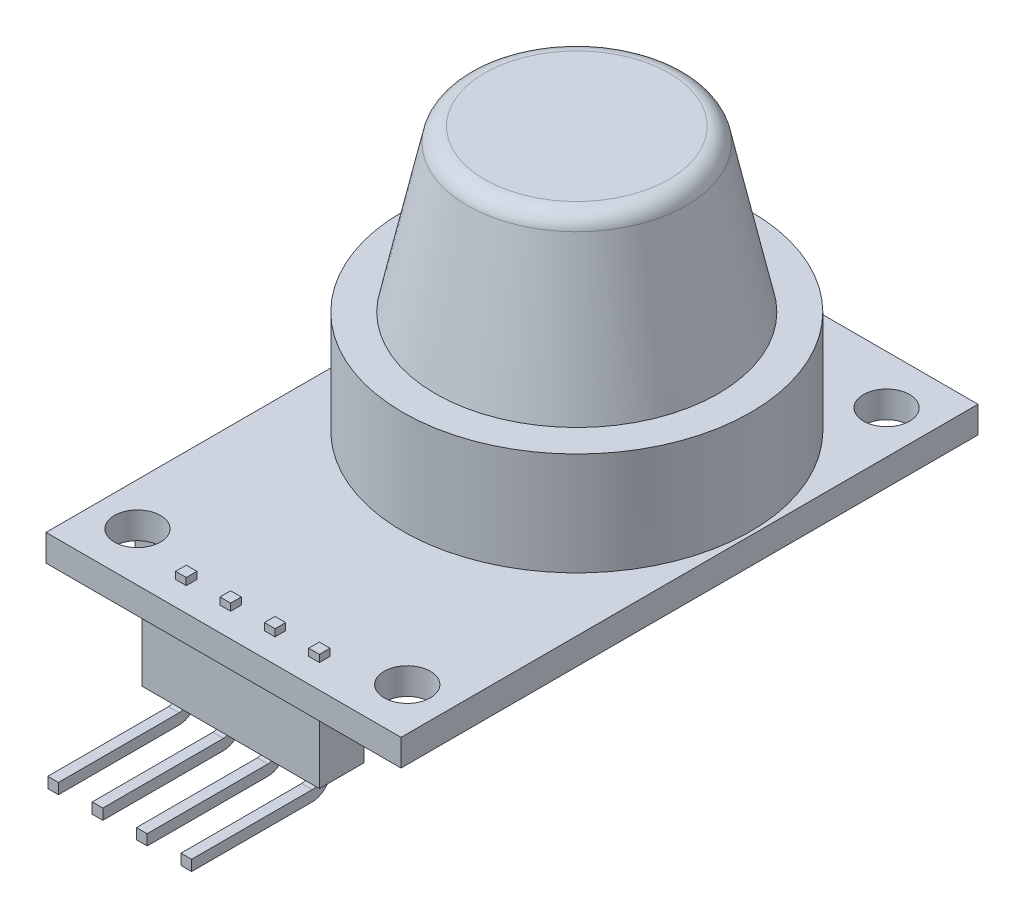
from build123d import *

# Parameters (mm, degrees)
SKETCH_1_W                 = 20
SKETCH_1_H                 = 32.5
SKETCH_1_R                 = 1.3
EXTRUDE_1_DEPTH            = 1.5
SKETCH_2_R                 = 9.8
EXTRUDE_2_DEPTH            = 5.8
FILLET_1_R                 = 1
SKETCH_4_W                 = 6.7
SKETCH_4_H                 = 6.7
EXTRUDE_3_DEPTH            = 4.8
SKETCH_5_R                 = 0.5
EXTRUDE_4_DEPTH            = 4.6
SKETCH_6_W                 = 2.5
SKETCH_6_H                 = 2.5
EXTRUDE_5_DEPTH            = 3.7
EXTRUDE_6_DEPTH            = 0.3
PATTERN_LINEAR_1_COUNT     = 3
PATTERN_LINEAR_1_PITCH     = 2.5
PATTERN_LINEAR_1_COL_COUNT = 2
PATTERN_LINEAR_1_COL_PITCH = 2.5


with BuildPart() as part:
    # 草图1 → 凸台-拉伸1 (new body)
    with BuildSketch(Plane(origin=(0, 0, 0), x_dir=(1, 0, 0), z_dir=(0, 1, 0))):
        Rectangle(SKETCH_1_W, SKETCH_1_H)
        with Locations((7.6, 13.5)):
            Circle(SKETCH_1_R, mode=Mode.SUBTRACT)
        with Locations((-7.6, 13.5)):
            Circle(SKETCH_1_R, mode=Mode.SUBTRACT)
        with Locations((-7.6, -13.5)):
            Circle(SKETCH_1_R, mode=Mode.SUBTRACT)
        with Locations((7.6, -13.5)):
            Circle(SKETCH_1_R, mode=Mode.SUBTRACT)
    extrude(amount=EXTRUDE_1_DEPTH)

    # 草图2 → 凸台-拉伸2 (add)
    with BuildSketch(Plane(origin=(0, 1.5, 0), x_dir=(1, 0, 0), z_dir=(0, 1, 0))):
        with Locations((0, 3.65)):
            Circle(SKETCH_2_R)
    extrude(amount=EXTRUDE_2_DEPTH)

    # 草图3 → 旋转1 (revolve)
    with BuildSketch(Plane(origin=(0, 0, 0), x_dir=(0, 0, -1), z_dir=(1, 0, 0))):
        Polygon((3.65, 7.163786099), (11.65, 7.163786099), (9.65, 16.363786099), (3.65, 16.363786099), align=None)
    revolve(axis=Axis((0, 2.048350332, -3.65), (0, 1, 0)))

    # 圆角1
    fillet_1_edges = [part.edges().sort_by_distance(p)[0] for p in [
        (0, 16.363786099, 2.35),
    ]]
    fillet(fillet_1_edges, radius=FILLET_1_R)

    # 草图4 → 凸台-拉伸3 (add)
    with BuildSketch(Plane.XZ):
        with Locations((-6.45, 8.1)):
            Rectangle(SKETCH_4_W, SKETCH_4_H)
    extrude(amount=EXTRUDE_3_DEPTH)

    # 草图5 → 凸台-拉伸4 (add)
    with BuildSketch(Plane.XZ):
        with Locations((4.75, -3.65)):
            Circle(SKETCH_5_R)
        with Locations((3.358757211, -7.008757211)):
            Circle(SKETCH_5_R)
        with Locations((-3.358757211, -7.008757211)):
            Circle(SKETCH_5_R)
        with Locations((-4.75, -3.65)):
            Circle(SKETCH_5_R)
        with Locations((-3.358757211, -0.291242789)):
            Circle(SKETCH_5_R)
        with Locations((3.358757211, -0.291242789)):
            Circle(SKETCH_5_R)
    extrude(amount=EXTRUDE_4_DEPTH)

    # 草图6 → 凸台-拉伸5 (add)
    with BuildSketch(Plane.XZ):
        with Locations((1.25, 14.6)):
            Rectangle(SKETCH_6_W, SKETCH_6_H)
    extrude_5 = extrude(amount=EXTRUDE_5_DEPTH)

    # 草图7 → 凸台-拉伸6 (add, symmetric)
    with BuildSketch(Plane(origin=(1.25, 0, 0), x_dir=(0, 0, -1), z_dir=(1, 0, 0))):
        with BuildLine():
            Line((-14.3, 1.9), (-14.9, 1.9))
            Line((-14.9, 1.9), (-14.9, -4.1))
            ThreePointArc((-14.9, -4.1), (-15.017157288, -4.382842712), (-15.3, -4.5))
            Line((-15.3, -4.5), (-22.1, -4.5))
            Line((-22.1, -4.5), (-22.1, -5.1))
            Line((-22.1, -5.1), (-15.3, -5.1))
            ThreePointArc((-15.3, -5.1), (-14.592893219, -4.807106781), (-14.3, -4.1))
            Line((-14.3, -4.1), (-14.3, 1.9))
        make_face()
    extrude_6 = extrude(amount=EXTRUDE_6_DEPTH, both=True)

    # 阵列(线性)1: 凸台-拉伸5, 凸台-拉伸6 ×3
    with Locations(*[(-i * PATTERN_LINEAR_1_PITCH, 0, 0) for i in range(1, PATTERN_LINEAR_1_COUNT)]):
        add(extrude_5)
        add(extrude_6)

    # 阵列(线性)1 col: 凸台-拉伸5, 凸台-拉伸6 ×2
    with Locations(*[(i * PATTERN_LINEAR_1_COL_PITCH, 0, 0) for i in range(1, PATTERN_LINEAR_1_COL_COUNT)]):
        add(extrude_5)
        add(extrude_6)


solid = part.part
